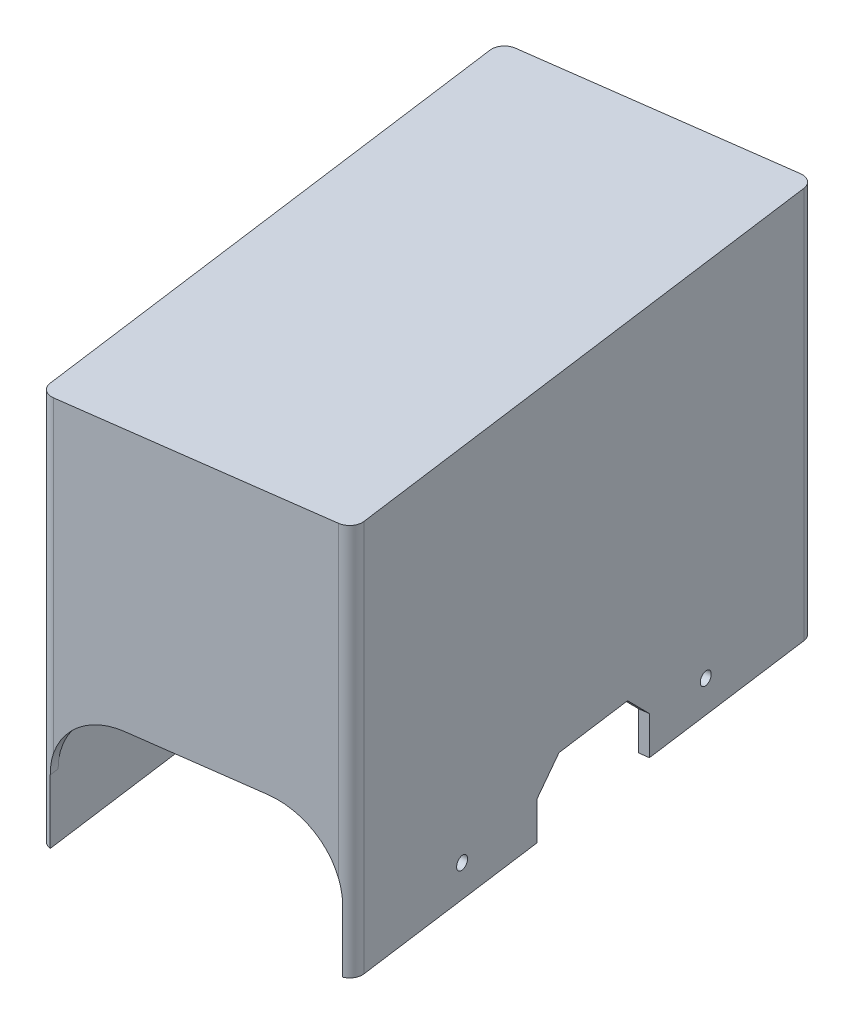
from build123d import *

# Parameters (mm, degrees)
BOSS_EXTRUDE1_DEPTH = 60
BOSS_EXTRUDE2_DEPTH = 1.5
CUT_EXTRUDE1_DEPTH  = 122.5
FILLET1_R           = 2
SKETCH4_R           = 1
CUT_EXTRUDE2_DEPTH  = 122.5
SKETCH5_W           = 20.552185026
SKETCH5_H           = 10
CUT_EXTRUDE3_DEPTH  = 66.5
CHAMFER2_SIZE       = 4


with BuildPart() as part:
    # Sketch1 → Boss-Extrude1 (new body)
    with BuildSketch(Plane(origin=(0, 0, 0), x_dir=(1, 0, 0), z_dir=(0, 1, 0))):
        Polygon((-25.683056898, 37.455662838), (17.724607753, 43.304991821), (29.01282847, -40.464497095), (-14.394836181, -46.313826078), align=None)
        Polygon((-23.996173554, 36.169418466), (16.438363381, 41.618108478), (27.325945127, -39.178252723), (-13.108591809, -44.626942734), align=None, mode=Mode.SUBTRACT)
    extrude(amount=BOSS_EXTRUDE1_DEPTH)

    # Sketch2 → Boss-Extrude2 (add)
    with BuildSketch(Plane(origin=(0, 60, 0), x_dir=(1, 0, 0), z_dir=(0, 1, 0))):
        Polygon((-25.683056898, 37.455662838), (-14.394836181, -46.313826078), (29.01282847, -40.464497095), (17.724607753, 43.304991821), align=None)
    extrude(amount=BOSS_EXTRUDE2_DEPTH)

    # Sketch3 → Cut-Extrude1 (cut)
    with BuildSketch(Plane(origin=(5.87291271, 0, 43.582678665), x_dir=(0.991042572, 0, -0.133546324), z_dir=(0.133546324, 0, 0.991042572))):
        with BuildLine():
            Line((21.449063315, 0), (21.449063315, 10))
            ThreePointArc((21.449063315, 10), (18.520131127, 17.071067812), (11.449063315, 20))
            Line((11.449063315, 20), (-8.550936685, 20))
            ThreePointArc((-8.550936685, 20), (-15.622004497, 17.071067812), (-18.550936685, 10))
            Line((-18.550936685, 10), (-18.550936685, 0))
            Line((-18.550936685, 0), (21.449063315, 0))
        make_face()
        with BuildLine():
            ThreePointArc((11.449063315, 20), (18.520131127, 17.071067812), (21.449063315, 10))
            Line((21.449063315, 10), (21.449063315, 0))
            Line((21.449063315, 0), (21.849063315, 0))
            Line((21.849063315, 0), (21.849063315, 10))
            ThreePointArc((21.849063315, 10), (18.802973839, 17.353910524), (11.449063315, 20.4))
            Line((11.449063315, 20.4), (-8.550936685, 20.4))
            ThreePointArc((-8.550936685, 20.4), (-15.90484721, 17.353910524), (-18.950936685, 10))
            Line((-18.950936685, 10), (-18.950936685, 0))
            Line((-18.950936685, 0), (-18.550936685, 0))
            Line((-18.550936685, 0), (-18.550936685, 10))
            ThreePointArc((-18.550936685, 10), (-15.622004497, 17.071067812), (-8.550936685, 20))
            Line((-8.550936685, 20), (11.449063315, 20))
        make_face()
    extrude(amount=-CUT_EXTRUDE1_DEPTH, mode=Mode.SUBTRACT)

    # Fillet1
    fillet1_edges = [part.edges().sort_by_distance(p)[0] for p in [
        (17.724607753, 30.75, -43.304991821),
        (-25.683056898, 30.75, -37.455662838),
        (-14.394836181, 30.75, 46.313826078),
        (29.01282847, 30.75, 40.464497095),
    ]]
    fillet(fillet1_edges, radius=FILLET1_R)

    # Sketch4 → Cut-Extrude2 (cut)
    with BuildSketch(Plane(origin=(23.13991576, 0, -3.11818157), x_dir=(-0.133546324, 0, -0.991042572), z_dir=(0.991042572, 0, -0.133546324))):
        with Locations((-24.013280796, 5)):
            Circle(SKETCH4_R)
        with Locations((20.586719204, 5)):
            Circle(SKETCH4_R)
    extrude(amount=-CUT_EXTRUDE2_DEPTH, mode=Mode.SUBTRACT)

    # Sketch5 → Cut-Extrude3 (cut)
    with BuildSketch(Plane(origin=(-20.267748891, 0, 2.731147413), x_dir=(0.133546324, 0, 0.991042572), z_dir=(-0.991042572, 0, 0.133546324))):
        with Locations((0, 5)):
            Rectangle(SKETCH5_W, SKETCH5_H)
    extrude(amount=-CUT_EXTRUDE3_DEPTH, mode=Mode.SUBTRACT)

    # Chamfer2
    chamfer2_edges = [part.edges().sort_by_distance(p)[0] for p in [
        (21.024299453, 10, -13.202066981),
        (-20.89680134, 10, -7.553057484),
        (23.768968209, 10, 7.166023327),
        (-18.152132584, 10, 12.815032824),
    ]]
    chamfer(chamfer2_edges, length=CHAMFER2_SIZE)


solid = part.part
